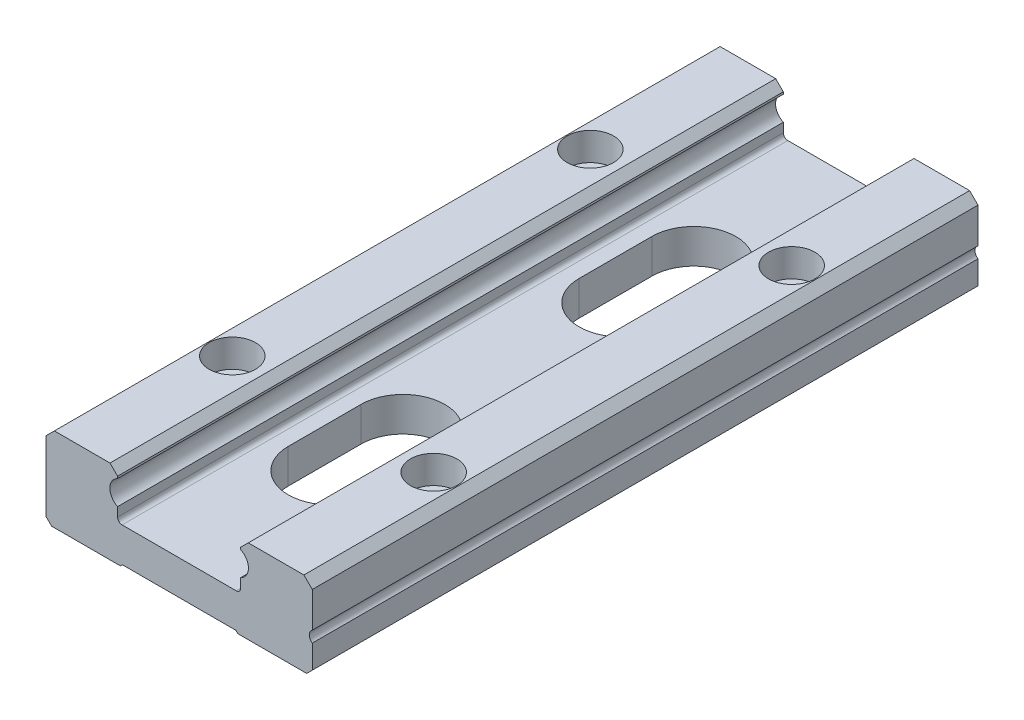
from build123d import *

# Parameters (mm, degrees)
EXTRUDE_1_DEPTH     = 119
SKETCH_4_R          = 4.145
CUT_EXTRUDE_2_DEPTH = 5
SKETCH_7_R          = 2.8
CUT_EXTRUDE_3_DEPTH = 10
CUT_EXTRUDE_4_DEPTH = 10


with BuildPart() as part:
    # 草图1 → 凸台-拉伸1 (new body)
    with BuildSketch(Plane.XY):
        Polygon((100.067060811, 682.684424639), (88.767060811, 682.684424639), (88.087771489, 683.363713961), (88.767060811, 684.043003282), (98.708482167, 684.043003282), align=None)
        Polygon((88.767060811, 682.684424639), (88.767060811, 670.543003282), (87.767060811, 669.543003282), (87.267060811, 670.043003282), (87.267060811, 682.543003282), (88.087771489, 683.363713961), align=None)
        with BuildLine():
            ThreePointArc((100.067060811, 682.308234217), (98.682060811, 680.143003282), (100.067060811, 677.977772348))
            Line((100.067060811, 677.977772348), (100.067060811, 676.343003282))
            ThreePointArc((100.067060811, 676.343003282), (100.301375386, 675.777317857), (100.867060811, 675.543003282))
            Line((100.867060811, 675.543003282), (121.267060811, 675.543003282))
            ThreePointArc((121.267060811, 675.543003282), (121.832746236, 675.777317857), (122.067060811, 676.343003282))
            Line((122.067060811, 676.343003282), (122.067060811, 677.977772348))
            ThreePointArc((122.067060811, 677.977772348), (123.452060811, 680.143003282), (122.067060811, 682.308234217))
            Line((122.067060811, 682.308234217), (122.067060811, 682.684424639))
            Line((122.067060811, 682.684424639), (133.367060811, 682.684424639))
            Line((133.367060811, 682.684424639), (133.367060811, 670.543003282))
            Line((133.367060811, 670.543003282), (88.767060811, 670.543003282))
            Line((88.767060811, 670.543003282), (88.767060811, 682.684424639))
            Line((88.767060811, 682.684424639), (100.067060811, 682.684424639))
            Line((100.067060811, 682.684424639), (100.067060811, 682.308234217))
        make_face()
        Polygon((88.767060811, 670.543003282), (133.367060811, 670.543003282), (134.367060811, 669.543003282), (133.867060811, 669.043003282), (121.567060811, 669.043003282), (121.217060811, 669.393003282), (100.917060811, 669.393003282), (100.567060811, 669.043003282), (88.267060811, 669.043003282), (87.767060811, 669.543003282), align=None)
        Polygon((133.367060811, 682.684424639), (122.067060811, 682.684424639), (123.425639455, 684.043003282), (123.667060811, 684.043003282), (133.367060811, 684.043003282), (134.046350133, 683.363713961), align=None)
        with BuildLine():
            ThreePointArc((134.867060811, 676.243003282), (134.330385769, 675.243003282), (134.867060811, 674.243003282))
            Line((134.867060811, 674.243003282), (134.867060811, 670.043003282))
            Line((134.867060811, 670.043003282), (134.367060811, 669.543003282))
            Line((134.367060811, 669.543003282), (133.367060811, 670.543003282))
            Line((133.367060811, 670.543003282), (133.367060811, 682.684424639))
            Line((133.367060811, 682.684424639), (134.046350133, 683.363713961))
            Line((134.046350133, 683.363713961), (134.867060811, 682.543003282))
            Line((134.867060811, 682.543003282), (134.867060811, 676.243003282))
        make_face()
    extrude(amount=EXTRUDE_1_DEPTH)

    # 草图4 → 切除-拉伸2 (cut)
    with BuildSketch(Plane(origin=(0, 684.043003282, 0), x_dir=(1, 0, 0), z_dir=(0, 1, 0))):
        with Locations((93.067060811, -27.5)):
            Circle(SKETCH_4_R)
        with Locations((129.067060811, -27.5)):
            Circle(SKETCH_4_R)
        with Locations((93.067060811, -91.5)):
            Circle(SKETCH_4_R)
        with Locations((129.067060811, -91.5)):
            Circle(SKETCH_4_R)
    extrude(amount=-CUT_EXTRUDE_2_DEPTH, mode=Mode.SUBTRACT)

    # 草图7 → 切除-拉伸3 (cut)
    with BuildSketch(Plane(origin=(0, 679.043003282, 0), x_dir=(1, 0, 0), z_dir=(0, 1, 0))):
        with Locations((93.067060811, -27.5)):
            Circle(SKETCH_7_R)
        with Locations((93.067060811, -91.5)):
            Circle(SKETCH_7_R)
        with Locations((129.067060811, -91.5)):
            Circle(SKETCH_7_R)
        with Locations((129.067060811, -27.5)):
            Circle(SKETCH_7_R)
    extrude(amount=-CUT_EXTRUDE_3_DEPTH, mode=Mode.SUBTRACT)

    # 草图8 → 切除-拉伸4 (cut)
    with BuildSketch(Plane(origin=(0, 675.543003282, 0), x_dir=(1, 0, 0), z_dir=(0, 1, 0))):
        with BuildLine():
            Line((103.567060811, -27), (103.567060811, -40))
            ThreePointArc((103.567060811, -40), (111.067060811, -47.5), (118.567060811, -40))
            Line((118.567060811, -40), (118.567060811, -27))
            ThreePointArc((118.567060811, -27), (111.067060811, -19.5), (103.567060811, -27))
        make_face()
        with BuildLine():
            Line((103.567060811, -79), (103.567060811, -92))
            ThreePointArc((103.567060811, -92), (111.067060811, -99.5), (118.567060811, -92))
            Line((118.567060811, -92), (118.567060811, -79))
            ThreePointArc((118.567060811, -79), (111.067060811, -71.5), (103.567060811, -79))
        make_face()
    extrude(amount=-CUT_EXTRUDE_4_DEPTH, mode=Mode.SUBTRACT)


solid = part.part
